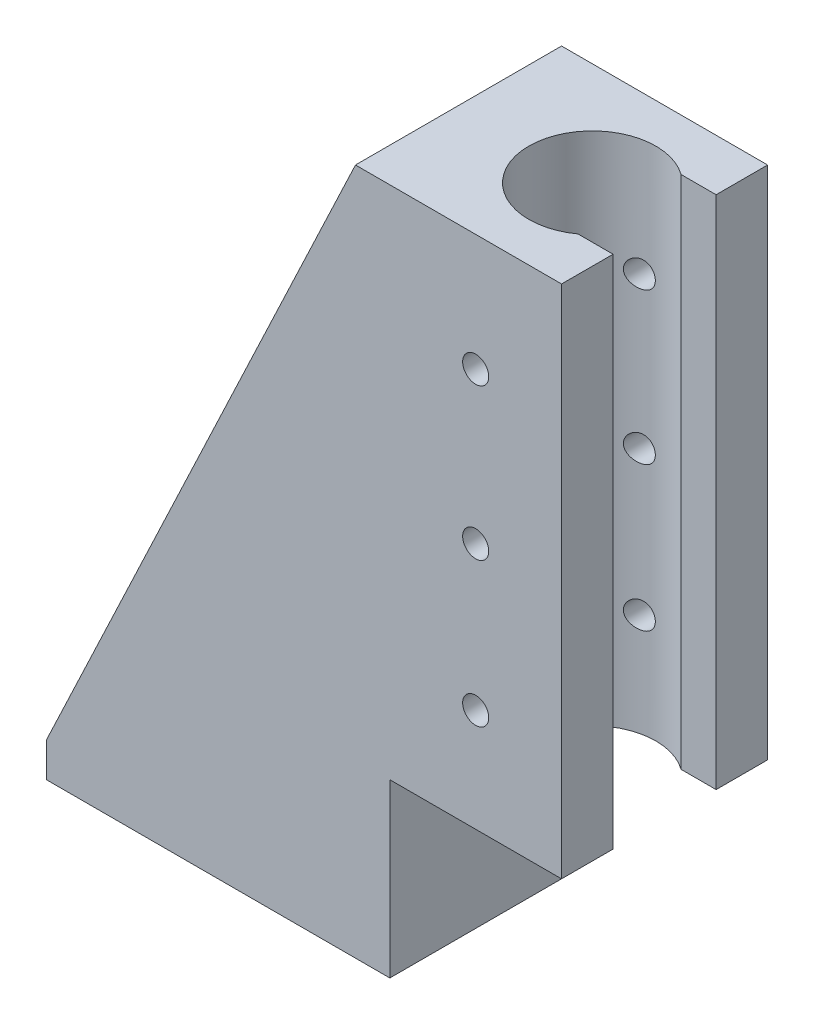
from build123d import *

# Parameters (mm, degrees)
BOSS_EXTRUDE1_DEPTH     = 19.05
BOSS_EXTRUDE2_DEPTH     = 95.25
SKETCH4_R               = 2.413
CUT_EXTRUDE1_DEPTH      = 1
CUT_EXTRUDE1_DEPTH_BACK = 39.1
SKETCH5_R               = 2.159
CUT_EXTRUDE2_DEPTH      = 121.6500001
CUT_EXTRUDE2_DEPTH_BACK = 7.35
BOSS_EXTRUDE3_DEPTH     = 3.175
FILLET1_R               = 6.35
FILLET2_R               = 3.175


with BuildPart() as part:
    # Sketch1 → Boss-Extrude1 (new body, symmetric)
    with BuildSketch(Plane.XY):
        Polygon((0, 0), (63.5, 0), (63.5, 127), (57.15, 127), (57.15, 6.35), (0, 6.35), align=None)
    extrude(amount=BOSS_EXTRUDE1_DEPTH, both=True)

    # Sketch3 → Boss-Extrude2 (add)
    with BuildSketch(Plane(origin=(0, 127, 0), x_dir=(1, 0, 0), z_dir=(0, 1, 0))):
        with BuildLine():
            Line((95.25, 19.05), (63.5, 19.05))
            Line((63.5, 19.05), (63.5, -19.05))
            Line((63.5, -19.05), (95.25, -19.05))
            Line((95.25, -19.05), (95.25, -9.525))
            Line((95.25, -9.525), (88.767695047, -9.525))
            ThreePointArc((88.767695047, -9.525), (70.144285562, 0), (88.767695047, 9.525))
            Line((88.767695047, 9.525), (95.25, 9.525))
            Line((95.25, 9.525), (95.25, 19.05))
        make_face()
    extrude(amount=-BOSS_EXTRUDE2_DEPTH)

    # Sketch4 → Cut-Extrude1 (cut, two sides)
    with BuildSketch(Plane.XY.offset(19.05)) as cut_extrude1_sk:
        with Locations((79.375, 105.41)):
            Circle(SKETCH4_R)
        with Locations((79.375, 50.8)):
            Circle(SKETCH4_R)
        with Locations((79.375, 77.47)):
            Circle(SKETCH4_R)
    extrude(amount=CUT_EXTRUDE1_DEPTH, mode=Mode.SUBTRACT)
    extrude(cut_extrude1_sk.sketch, amount=-CUT_EXTRUDE1_DEPTH_BACK, mode=Mode.SUBTRACT)

    # Sketch5 → Cut-Extrude2 (cut, two sides)
    with BuildSketch(Plane(origin=(0, 6.35, 0), x_dir=(1, 0, 0), z_dir=(0, 1, 0))) as cut_extrude2_sk:
        with Locations((12.7, 10.16)):
            Circle(SKETCH5_R)
        with Locations((44.45, -10.16)):
            Circle(SKETCH5_R)
    extrude(amount=CUT_EXTRUDE2_DEPTH, mode=Mode.SUBTRACT)
    extrude(cut_extrude2_sk.sketch, amount=-CUT_EXTRUDE2_DEPTH_BACK, mode=Mode.SUBTRACT)

    # Sketch6 → Boss-Extrude3 (add)
    with BuildSketch(Plane.XY.offset(19.05)):
        Polygon((57.15, 127), (0, 6.35), (57.15, 6.35), align=None)
    boss_extrude3 = extrude(amount=-BOSS_EXTRUDE3_DEPTH)

    # Mirror1: Boss-Extrude3 across plane
    add(boss_extrude3.mirror(Plane.XY))

    # Fillet1
    fillet1_edges = [part.edges().sort_by_distance(p)[0] for p in [
        (57.15, 6.35, 0),
    ]]
    fillet(fillet1_edges, radius=FILLET1_R)

    # Fillet2
    fillet2_edges = [part.edges().sort_by_distance(p)[0] for p in [
        (25.4, 6.35, -15.875),
        (25.4, 6.35, 15.875),
        (55.290128061, 8.209871939, -15.875),
        (55.290128061, 8.209871939, 15.875),
        (57.15, 69.85, 15.875),
        (57.15, 69.85, -15.875),
    ]]
    fillet(fillet2_edges, radius=FILLET2_R)


solid = part.part
